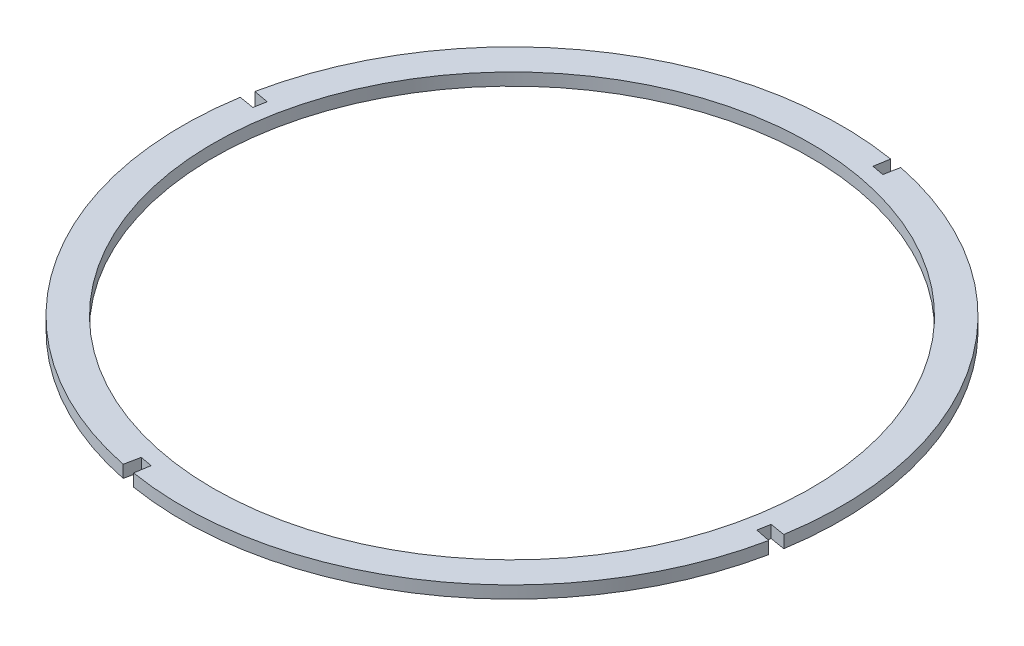
from build123d import *

# Parameters (mm, degrees)
SKETCH_1_R      = 388.53
EXTRUDE_2_DEPTH = 16


with BuildPart() as part:
    # Эскиз1 → Бобышка-Вытянуть2 (new body)
    with BuildSketch(Plane(origin=(0, 0, 0), x_dir=(1, 0, 0), z_dir=(0, 1, 0))):
        with BuildLine():
            Line((-414.416497784, 590.478186418), (-398.681994202, 587.575532974))
            Line((-398.681994202, 587.575532974), (-395.067225603, 607.17022127))
            ThreePointArc((-395.067225603, 607.17022127), (-127.813365795, 430.452815829), (-57.802574586, 117.799403754))
            Line((-57.802574586, 117.799403754), (-77.460685724, 121.029251476))
            Line((-77.460685724, 121.029251476), (-80.363339169, 105.294747893))
            Line((-80.363339169, 105.294747893), (-60.846746751, 101.297765253))
            ThreePointArc((-60.846746751, 101.297765253), (-237.544696024, -165.614286652), (-549.895048486, -235.624757623))
            Line((-549.895048486, -235.624757623), (-546.676939726, -215.967081375))
            Line((-546.676939726, -215.967081375), (-562.412281664, -213.068976114))
            Line((-562.412281664, -213.068976114), (-566.398442354, -232.590123996))
            ThreePointArc((-566.398442354, -232.590123996), (-833.553158398, -55.842550862), (-903.523543866, 256.75222208))
            Line((-903.523543866, 256.75222208), (-883.865432727, 253.522374358))
            Line((-883.865432727, 253.522374358), (-880.962779283, 269.256877941))
            Line((-880.962779283, 269.256877941), (-900.557467579, 272.87164654))
            ThreePointArc((-900.557467579, 272.87164654), (-723.840062138, 540.125506348), (-411.186650063, 610.136297557))
            Line((-411.186650063, 610.136297557), (-414.416497784, 590.478186418))
        make_face()
        with Locations((-480.663059226, 187.275812917)):
            Circle(SKETCH_1_R, mode=Mode.SUBTRACT)
    extrude(amount=EXTRUDE_2_DEPTH)


solid = part.part
